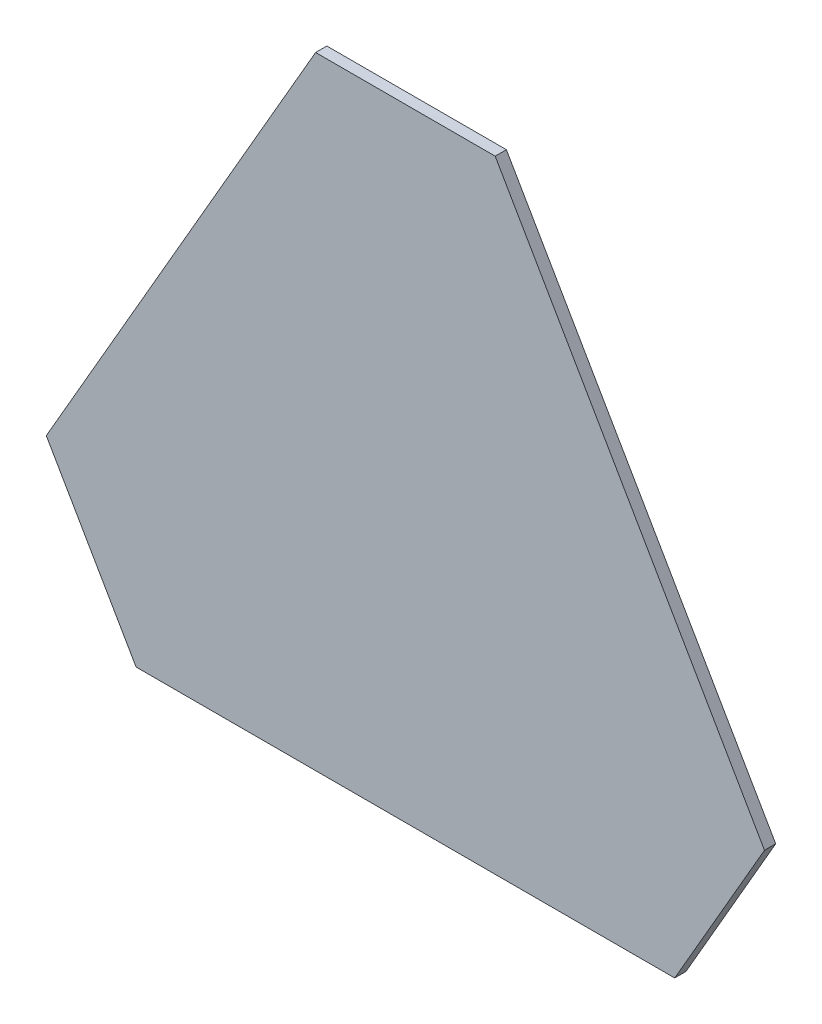
from build123d import *

# Parameters (mm, degrees)
BOSS_EXTRUDE1_DEPTH = 5


with BuildPart() as part:
    # Sketch1 → Boss-Extrude1 (new body)
    with BuildSketch(Plane.XY):
        Polygon((0, 0), (240, 0), (280, 69.282032303), (160, 277.128129211), (80, 277.128129211), (-40, 69.282032303), align=None)
    extrude(amount=BOSS_EXTRUDE1_DEPTH)


solid = part.part
